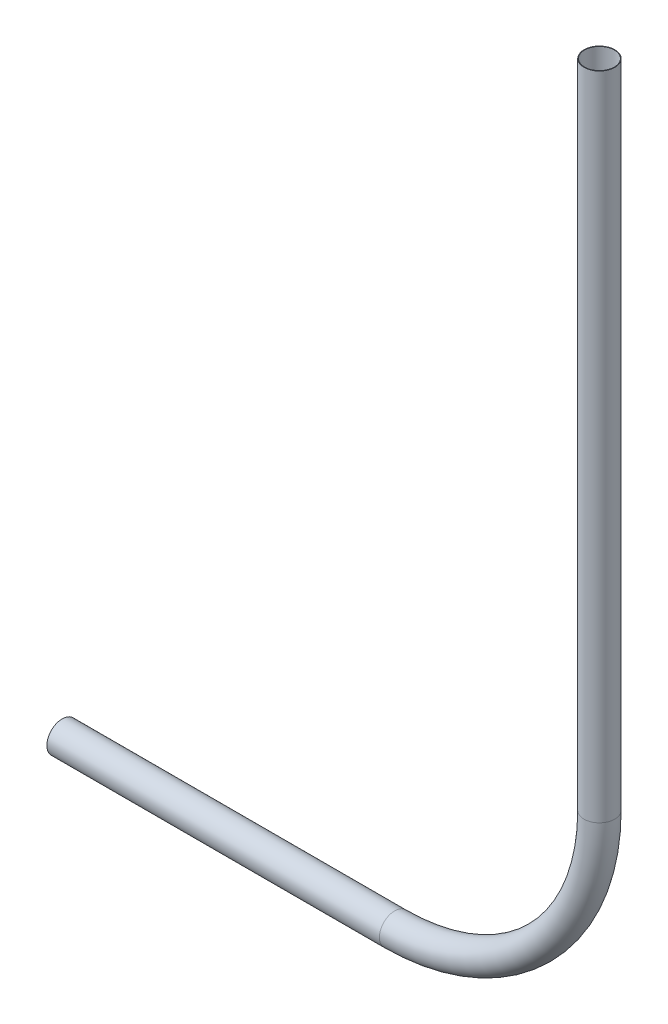
from build123d import *

# Parameters (mm, degrees)
SWEEP_THIN1_PROFILE_R   = 30
SWEEP_THIN1_PROFILE_R_2 = 29


with BuildPart() as part:
    # Sweep-Thin1: sweep along a curve in space
    with BuildLine() as sweep_thin1_path:
        Line((-22963.540820266, -7934.109647753, 40217.801947749), (-22313.789024318, -7934.109647753, 40217.801947749))
        ThreePointArc((-21913.789024318, -7534.109647753, 40217.801947749), (-22030.946311844, -7816.952360228, 40217.801947749), (-22313.789024318, -7934.109647753, 40217.801947749))
        Line((-21913.789024318, -7534.109647753, 40217.801947749), (-21913.789024318, -6261.81040257, 40217.801947749))
    # Sweep-Thin1 profile (on start of the path) → Sweep-Thin1 (sweep)
    with BuildSketch(Plane(origin=(-22963.540820266, -7934.109647753, 40217.801947749), x_dir=(0, 0, 1), z_dir=(1, 0, 0))):
        Circle(SWEEP_THIN1_PROFILE_R)
        Circle(SWEEP_THIN1_PROFILE_R_2, mode=Mode.SUBTRACT)
    sweep(path=sweep_thin1_path.line)


solid = part.part
